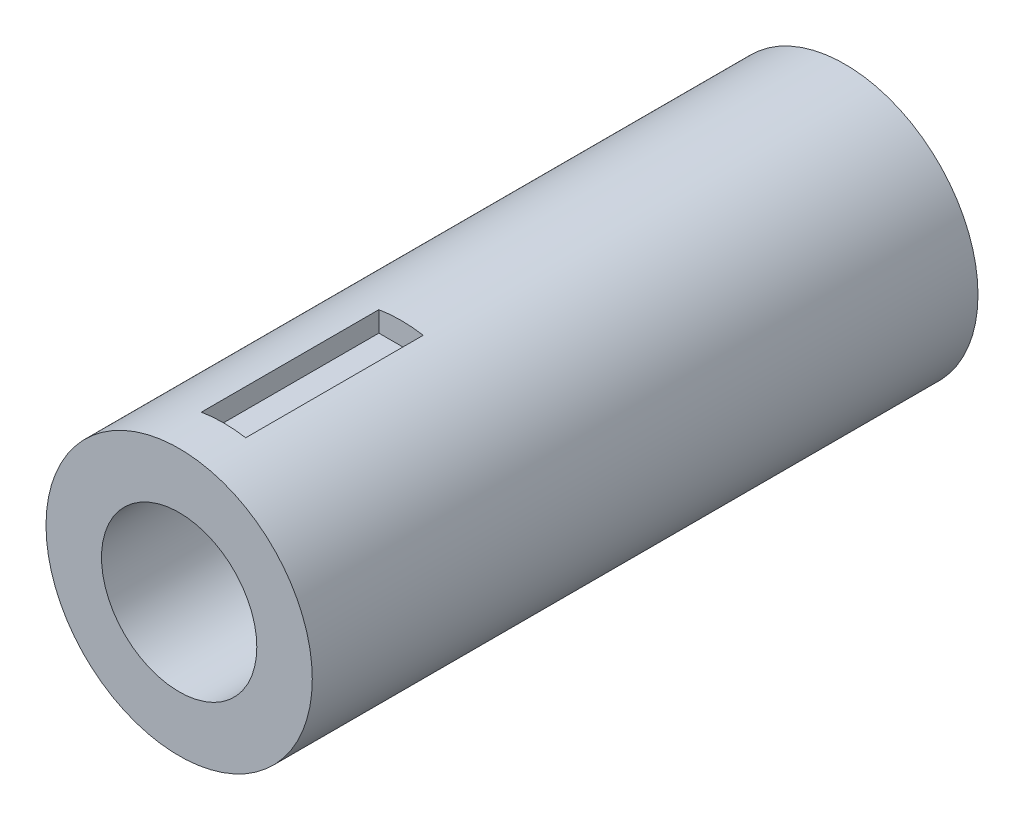
from build123d import *

# Parameters (mm, degrees)
SKETCH1_R           = 6
SKETCH1_R_2         = 3.5
BOSS_EXTRUDE1_DEPTH = 30
SKETCH3_W           = 2
SKETCH3_H           = 8
CUT_EXTRUDE1_DEPTH  = 1


with BuildPart() as part:
    # Sketch1 → Boss-Extrude1 (new body)
    with BuildSketch(Plane.XY):
        Circle(SKETCH1_R)
        Circle(SKETCH1_R_2, mode=Mode.SUBTRACT)
    extrude(amount=-BOSS_EXTRUDE1_DEPTH)

    # Sketch3 → Cut-Extrude1 (cut)
    with BuildSketch(Plane(origin=(0, 6, 0), x_dir=(1, 0, 0), z_dir=(0, 1, 0))):
        with Locations((0, 6)):
            Rectangle(SKETCH3_W, SKETCH3_H)
    extrude(amount=-CUT_EXTRUDE1_DEPTH, mode=Mode.SUBTRACT)


solid = part.part
